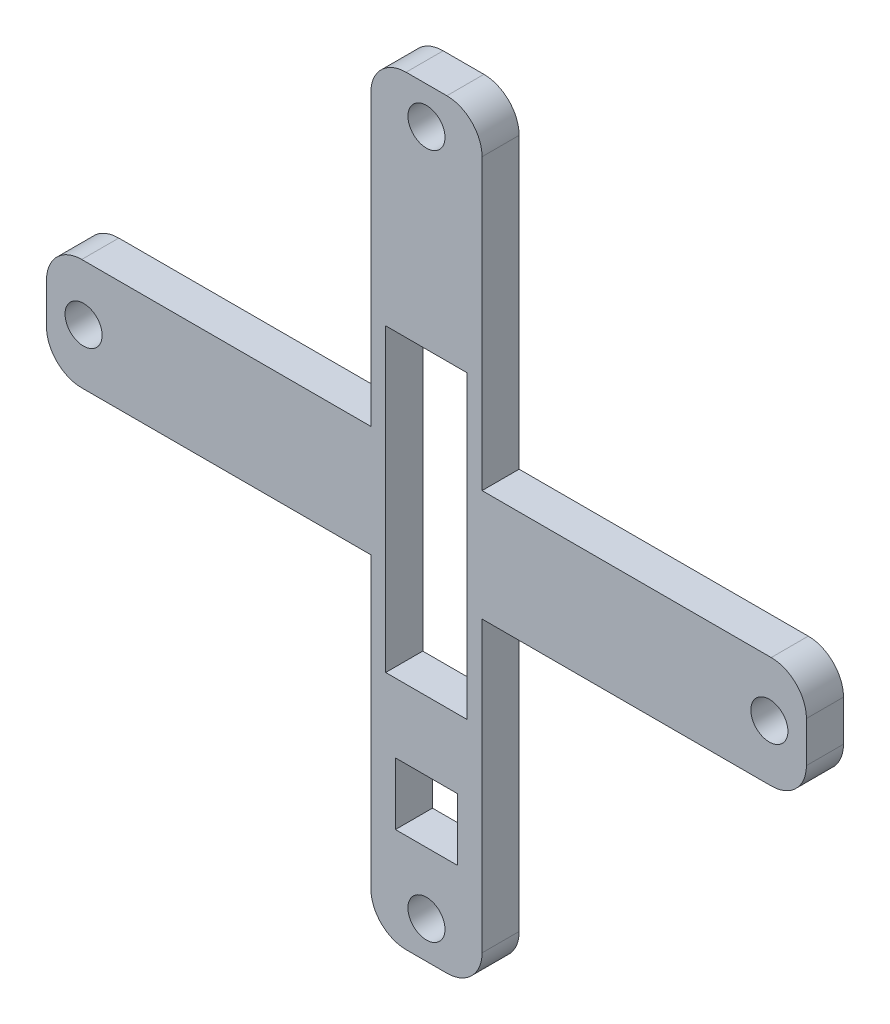
from build123d import *

# Parameters (mm, degrees)
CROQUIS1_R              = 1
CROQUIS1_W              = 3.35
CROQUIS1_H              = 3.35
CROQUIS1_W_2            = 4.4
CROQUIS1_H_2            = 16.2
SALIENTE_EXTRUIR1_DEPTH = 2


with BuildPart() as part:
    # Croquis1 → Saliente-Extruir1 (new body)
    with BuildSketch(Plane.XY):
        with BuildLine():
            Line((-3, 3), (-3, 18.6))
            ThreePointArc((-3, 18.6), (-2.443502884, 19.943502884), (-1.1, 20.5))
            Line((-1.1, 20.5), (1.1, 20.5))
            ThreePointArc((1.1, 20.5), (2.443502884, 19.943502884), (3, 18.6))
            Line((3, 18.6), (3, 3))
            Line((3, 3), (18.6, 3))
            ThreePointArc((18.6, 3), (19.943502884, 2.443502884), (20.5, 1.1))
            Line((20.5, 1.1), (20.5, -1.1))
            ThreePointArc((20.5, -1.1), (19.943502884, -2.443502884), (18.6, -3))
            Line((18.6, -3), (3, -3))
            Line((3, -3), (3, -18.6))
            ThreePointArc((3, -18.6), (2.443502884, -19.943502884), (1.1, -20.5))
            Line((1.1, -20.5), (-1.1, -20.5))
            ThreePointArc((-1.1, -20.5), (-2.443502884, -19.943502884), (-3, -18.6))
            Line((-3, -18.6), (-3, -3))
            Line((-3, -3), (-18.6, -3))
            ThreePointArc((-18.6, -3), (-19.943502884, -2.443502884), (-20.5, -1.1))
            Line((-20.5, -1.1), (-20.5, 1.1))
            ThreePointArc((-20.5, 1.1), (-19.943502884, 2.443502884), (-18.6, 3))
            Line((-18.6, 3), (-3, 3))
        make_face()
        with Locations((0, 18.5)):
            Circle(CROQUIS1_R, mode=Mode.SUBTRACT)
        with Locations((18.5, 0)):
            Circle(CROQUIS1_R, mode=Mode.SUBTRACT)
        with Locations((0, -18.5)):
            Circle(CROQUIS1_R, mode=Mode.SUBTRACT)
        with Locations((-18.5, 0)):
            Circle(CROQUIS1_R, mode=Mode.SUBTRACT)
        with Locations((0, -13.5)):
            Rectangle(CROQUIS1_W, CROQUIS1_H, mode=Mode.SUBTRACT)
        Rectangle(CROQUIS1_W_2, CROQUIS1_H_2, mode=Mode.SUBTRACT)
    extrude(amount=SALIENTE_EXTRUIR1_DEPTH)


solid = part.part
